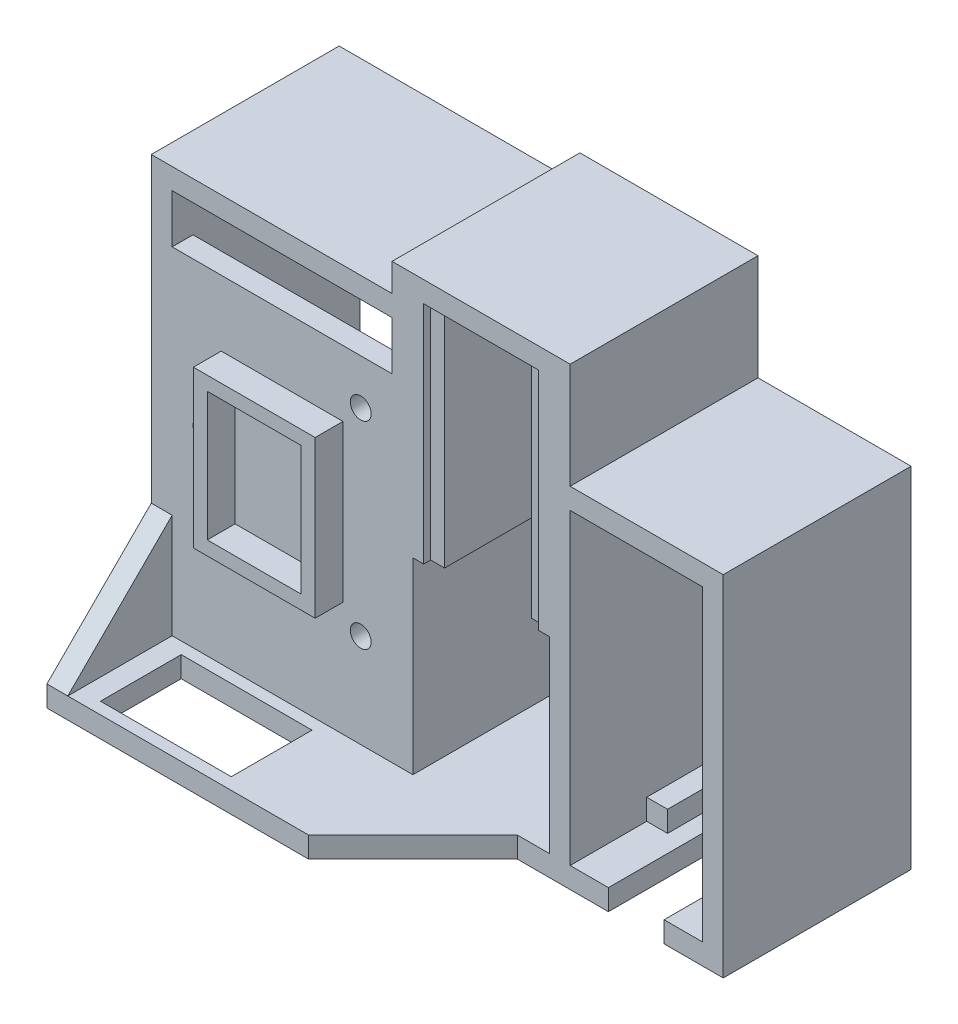
from build123d import *

# Parameters (mm, degrees)
SKETCH1_W            = 2
SKETCH1_H            = 32.4
SKETCH1_W_2          = 5
SKETCH1_H_2          = 3
SKETCH1_W_3          = 3
SKETCH1_W_4          = 8
BOSS_EXTRUDE1_DEPTH  = 3
BOSS_EXTRUDE2_DEPTH  = 27
SKETCH1_4_W          = 5
SKETCH1_4_H          = 3
SKETCH1_4_W_2        = 3
BOSS_EXTRUDE3_DEPTH  = 16
SKETCH1_5_W          = 8
SKETCH1_5_H          = 3
BOSS_EXTRUDE4_DEPTH  = 11
SKETCH1_6_W          = 2
SKETCH1_6_H          = 32.4
BOSS_EXTRUDE5_DEPTH  = 26
BOSS_EXTRUDE6_DEPTH  = 27
SKETCH3_W            = 31.6
SKETCH3_H            = 48.4
BOSS_EXTRUDE7_DEPTH  = 3
BOSS_EXTRUDE8_DEPTH  = 3
BOSS_EXTRUDE9_DEPTH  = 3
SKETCH6_R            = 1.5
CUT_EXTRUDE1_DEPTH   = 10
SKETCH7_W            = 2
SKETCH7_H            = 9.25
BOSS_EXTRUDE10_DEPTH = 4


with BuildPart() as part:
    # Sketch1 → Boss-Extrude1 (new body)
    with BuildSketch(Plane.XY):
        Polygon((3, 0), (0, 0), (-3, 0), (-22.6, 0), (-22.6, 27), (-25.6, 27), (-25.6, -3), (0, -3), (5.5, -3), (5.5, 0), align=None)
        Polygon((0, 62.4), (0, 47.2), (0, 44.2), (0, 41.2), (0, 3), (0, 0), (-3, 0), (-3, 27), (-4.55, 27), (-4.55, 59.4), (-21.05, 59.4), (-21.05, 27), (-22.6, 27), (-25.6, 27), (-25.6, 59.4), (-25.6, 62.4), (-4.55, 62.4), align=None)
        with Locations((-20.05, 43.2)):
            Rectangle(SKETCH1_W, SKETCH1_H)
        Polygon((-22.6, 0), (-3, 0), (-3, 27), (-4.55, 27), (-6.55, 27), (-6.55, 59.4), (-19.05, 59.4), (-19.05, 27), (-21.05, 27), (-22.6, 27), align=None)
        with Locations((2.5, 42.7)):
            Rectangle(SKETCH1_W_2, SKETCH1_H_2)
        Polygon((0, 47.2), (0, 44.2), (5, 44.2), (14, 44.2), (19, 44.2), (19, 41.2), (19, 3), (19, 0), (22, 0), (22, 44.2), (22, 47.2), align=None)
        with Locations((16.5, 42.7)):
            Rectangle(SKETCH1_W_2, SKETCH1_H_2)
        Polygon((3, 3), (3, 0), (5.5, 0), (13.5, 0), (16, 0), (16, 3), (19, 3), (19, 41.2), (14, 41.2), (14, 44.2), (5, 44.2), (5, 41.2), (0, 41.2), (0, 3), align=None)
        with Locations((17.5, 1.5)):
            Rectangle(SKETCH1_W_3, SKETCH1_H_2)
        Polygon((16, 0), (13.5, 0), (13.5, -3), (22, -3), (22, 0), (19, 0), align=None)
        with Locations((1.5, 1.5)):
            Rectangle(SKETCH1_W_3, SKETCH1_H_2)
        with Locations((9.5, -1.5)):
            Rectangle(SKETCH1_W_4, SKETCH1_H_2)
        with Locations((-5.55, 43.2)):
            Rectangle(SKETCH1_W, SKETCH1_H)
    extrude(amount=BOSS_EXTRUDE1_DEPTH)

    # Sketch1_3 → Boss-Extrude2 (add)
    with BuildSketch(Plane.XY):
        Polygon((0, 62.4), (0, 47.2), (0, 44.2), (0, 41.2), (0, 3), (0, 0), (-3, 0), (-3, 27), (-4.55, 27), (-4.55, 59.4), (-21.05, 59.4), (-21.05, 27), (-22.6, 27), (-25.6, 27), (-25.6, 59.4), (-25.6, 62.4), (-4.55, 62.4), align=None)
        Polygon((3, 0), (0, 0), (-3, 0), (-22.6, 0), (-22.6, 27), (-25.6, 27), (-25.6, -3), (0, -3), (5.5, -3), (5.5, 0), align=None)
        Polygon((16, 0), (13.5, 0), (13.5, -3), (22, -3), (22, 0), (19, 0), align=None)
        Polygon((0, 47.2), (0, 44.2), (5, 44.2), (14, 44.2), (19, 44.2), (19, 41.2), (19, 3), (19, 0), (22, 0), (22, 44.2), (22, 47.2), align=None)
    extrude(amount=BOSS_EXTRUDE2_DEPTH)

    # Sketch1_4 → Boss-Extrude3 (add)
    with BuildSketch(Plane.XY):
        with Locations((2.5, 42.7)):
            Rectangle(SKETCH1_4_W, SKETCH1_4_H)
        with Locations((16.5, 42.7)):
            Rectangle(SKETCH1_4_W, SKETCH1_4_H)
        with Locations((17.5, 1.5)):
            Rectangle(SKETCH1_4_W_2, SKETCH1_4_H)
        with Locations((1.5, 1.5)):
            Rectangle(SKETCH1_4_W_2, SKETCH1_4_H)
    extrude(amount=BOSS_EXTRUDE3_DEPTH)

    # Sketch1_5 → Boss-Extrude4 (add)
    with BuildSketch(Plane.XY):
        with Locations((9.5, -1.5)):
            Rectangle(SKETCH1_5_W, SKETCH1_5_H)
    extrude(amount=BOSS_EXTRUDE4_DEPTH)

    # Sketch1_6 → Boss-Extrude5 (add)
    with BuildSketch(Plane.XY):
        with Locations((-5.55, 43.2)):
            Rectangle(SKETCH1_6_W, SKETCH1_6_H)
        with Locations((-20.05, 43.2)):
            Rectangle(SKETCH1_6_W, SKETCH1_6_H)
    extrude(amount=BOSS_EXTRUDE5_DEPTH)

    # Sketch2 → Boss-Extrude6 (add)
    with BuildSketch(Plane(origin=(0, 0, 0), x_dir=(-1, 0, 0), z_dir=(0, 0, -1))):
        Polygon((25.6, 0), (25.6, -3), (60.2, -3), (60.2, 58.4), (25.6, 58.4), (25.6, 55.4), (57.2, 55.4), (57.2, 48.4), (57.2, 0), align=None)
    extrude(amount=-BOSS_EXTRUDE6_DEPTH)

    # Sketch3 → Boss-Extrude7 (add)
    with BuildSketch(Plane.XY.offset(27)):
        with Locations((-41.4, 24.2)):
            Rectangle(SKETCH3_W, SKETCH3_H)
    extrude(amount=-BOSS_EXTRUDE7_DEPTH)

    # Sketch4 → Boss-Extrude8 (add)
    with BuildSketch(Plane(origin=(0, -3, 0), x_dir=(-1, 0, 0), z_dir=(0, -1, 0))):
        Polygon((22.6, -42), (22.6, -27), (7.6, -27), align=None)
        Polygon((53.32802139, -27), (22.6, -27), (22.6, -42), (60.2, -42), (60.2, -32.991669089), (54.2, -32.991669089), (54.2, -40.3), (35.4, -40.3), (35.4, -28.7), (53.32802139, -28.7), align=None)
        Polygon((60.2, -27), (53.32802139, -27), (53.32802139, -28.7), (54.2, -28.7), (54.2, -32.991669089), (60.2, -32.991669089), align=None)
    extrude(amount=-BOSS_EXTRUDE8_DEPTH)

    # Sketch5 → Boss-Extrude9 (add)
    with BuildSketch(Plane.ZY.offset(60.2)):
        Polygon((27, 0), (42, 0), (27, 15), align=None)
    extrude(amount=-BOSS_EXTRUDE9_DEPTH)

    # Sketch6 → Cut-Extrude1 (cut)
    with BuildSketch(Plane(origin=(0, 0, 24), x_dir=(-1, 0, 0), z_dir=(0, 0, -1))):
        with Locations((30.1, 41.9)):
            Circle(SKETCH6_R)
        with Locations((30.1, 13.5)):
            Circle(SKETCH6_R)
        with Locations((52.7, 27.7)):
            Circle(SKETCH6_R)
    extrude(amount=-CUT_EXTRUDE1_DEPTH, mode=Mode.SUBTRACT)

    # Sketch7 → Boss-Extrude10 (add)
    with BuildSketch(Plane.XY.offset(27)):
        Polygon((-50.15, 38.95), (-50.15, 27.7), (-48.15, 27.7), (-48.15, 36.95), (-41.4, 36.95), (-34.65, 36.95), (-34.65, 27.7), (-32.65, 27.7), (-32.65, 36.95), (-32.65, 38.95), (-48.15, 38.95), align=None)
        Polygon((-48.15, 27.7), (-50.15, 27.7), (-50.15, 18.45), (-50.15, 16.45), (-32.65, 16.45), (-32.65, 18.45), (-34.65, 18.45), (-41.4, 18.45), (-48.15, 18.45), align=None)
        with Locations((-33.65, 23.075)):
            Rectangle(SKETCH7_W, SKETCH7_H)
    extrude(amount=BOSS_EXTRUDE10_DEPTH)


solid = part.part
